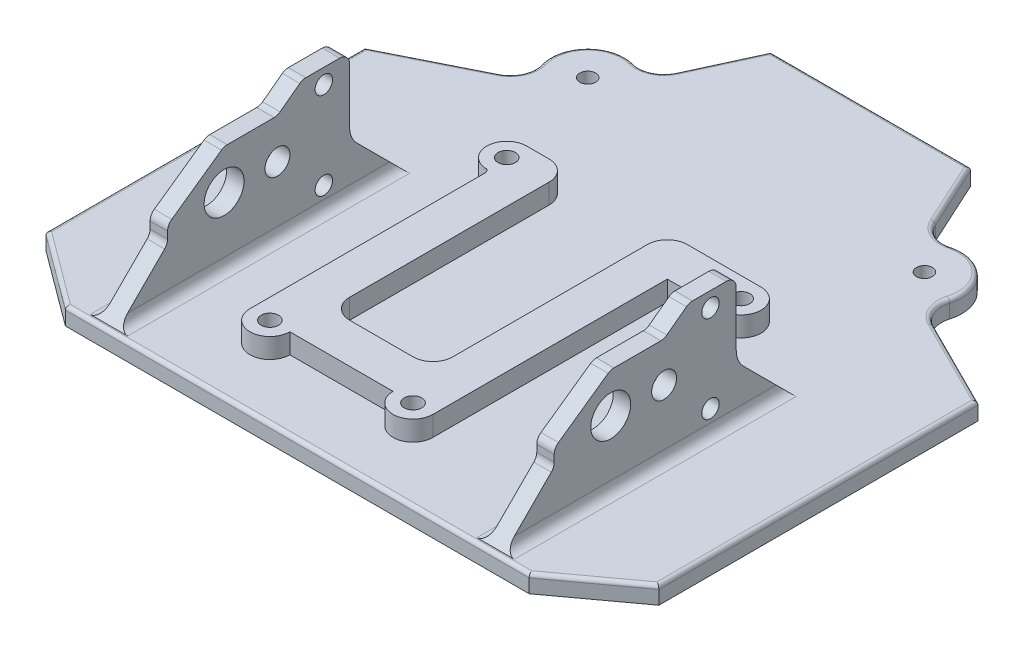
from build123d import *

# Parameters (mm, degrees)
BOSS_EXTRUDE1_DEPTH = 3.5
SKETCH2_W           = 3.5
SKETCH2_H           = 36.5
BOSS_EXTRUDE2_DEPTH = 25
CHAMFER1_SIZE       = 10
FILLET1_R           = 2
SKETCH3_R           = 1.75
CUT_EXTRUDE1_DEPTH  = 108
FILLET2_R           = 2
SKETCH4_R           = 4
SKETCH4_R_2         = 2.5
CUT_EXTRUDE2_DEPTH  = 108
CUT_EXTRUDE3_DEPTH  = 108
FILLET3_R           = 2
FILLET4_R           = 5
SKETCH6_R           = 1.75
BOSS_EXTRUDE3_DEPTH = 4
SKETCH7_R           = 1.75
CUT_EXTRUDE4_DEPTH  = 37
CHAMFER2_SIZE       = 2.5
CHAMFER2_SIZE2      = 2
CUT_EXTRUDE5_DEPTH  = 37
SKETCH9_R           = 1.6
BOSS_EXTRUDE4_DEPTH = 3.5
FILLET5_R           = 5
FILLET6_R           = 0.75


with BuildPart() as part:
    # Sketch1 → Boss-Extrude1 (new body)
    with BuildSketch(Plane(origin=(0, 0, 0), x_dir=(1, 0, 0), z_dir=(0, 1, 0))):
        Polygon((0, 0), (63, 0), (93, 0), (93, 75), (63, 90), (51.5, 115), (31.5, 115), (11.5, 115), (0, 90), (-30, 75), (-30, 0), align=None)
    extrude(amount=BOSS_EXTRUDE1_DEPTH)

    # Sketch2 → Boss-Extrude2 (add)
    with BuildSketch(Plane(origin=(0, 3.5, 0), x_dir=(1, 0, 0), z_dir=(0, 1, 0))):
        with Locations((-7.267018522, 29.254092769)):
            Rectangle(SKETCH2_W, SKETCH2_H)
        with Locations((70.267018522, 29.254092769)):
            Rectangle(SKETCH2_W, SKETCH2_H)
    extrude(amount=BOSS_EXTRUDE2_DEPTH)

    # Chamfer1
    chamfer1_edges = [part.edges().sort_by_distance(p)[0] for p in [
        (-7.267018522, 3.5, -11.004092769),
        (-7.267018522, 3.5, -47.504092769),
        (70.267018522, 3.5, -11.004092769),
        (70.267018522, 3.5, -47.504092769),
    ]]
    chamfer(chamfer1_edges, length=CHAMFER1_SIZE)

    # Fillet1
    fillet1_edges = [part.edges().sort_by_distance(p)[0] for p in [
        (-5.517018522, 3.5, -29.254092769),
        (68.517018522, 3.5, -29.254092769),
    ]]
    fillet(fillet1_edges, radius=FILLET1_R)

    # Sketch3 → Cut-Extrude1 (cut)
    with BuildSketch(Plane(origin=(72.017018522, 0, 0), x_dir=(0, 0, -1), z_dir=(1, 0, 0))):
        with Locations((42.33980963, 25.5)):
            Circle(SKETCH3_R)
        with Locations((42.33980963, 8)):
            Circle(SKETCH3_R)
    extrude(amount=-CUT_EXTRUDE1_DEPTH, mode=Mode.SUBTRACT)

    # Fillet2
    fillet2_edges = [part.edges().sort_by_distance(p)[0] for p in [
        (-9.017018522, 3.5, -29.254092769),
        (72.017018522, 3.5, -29.254092769),
    ]]
    fillet(fillet2_edges, radius=FILLET2_R)

    # Sketch4 → Cut-Extrude2 (cut)
    with BuildSketch(Plane(origin=(72.017018522, 0, 0), x_dir=(0, 0, -1), z_dir=(1, 0, 0))):
        with Locations((22.33980963, 16.75)):
            Circle(SKETCH4_R)
        with Locations((33.03980963, 16.75)):
            Circle(SKETCH4_R_2)
    extrude(amount=-CUT_EXTRUDE2_DEPTH, mode=Mode.SUBTRACT)

    # Sketch5 → Cut-Extrude3 (cut)
    with BuildSketch(Plane(origin=(72.017018522, 0, 0), x_dir=(0, 0, -1), z_dir=(1, 0, 0))):
        Polygon((22.33980963, 24.747503661), (11.004092769, 16.75), (11.004092769, 28.5), (38.0603401, 28.5), (33.03980963, 24.747503661), align=None)
    extrude(amount=-CUT_EXTRUDE3_DEPTH, mode=Mode.SUBTRACT)

    # Fillet3
    fillet3_edges = [part.edges().sort_by_distance(p)[0] for p in [
        (70.267018522, 28.5, -38.0603401),
        (-7.267018522, 24.747503661, -33.03980963),
        (70.267018522, 24.747503661, -33.03980963),
        (-7.267018522, 24.747503661, -22.33980963),
        (70.267018522, 24.747503661, -22.33980963),
        (-7.267018522, 28.5, -38.0603401),
        (-7.267018522, 16.75, -11.004092769),
        (70.267018522, 16.75, -11.004092769),
        (-7.267018522, 28.5, -47.504092769),
        (70.267018522, 28.5, -47.504092769),
        (-7.267018522, 13.5, -11.004092769),
        (70.267018522, 13.5, -11.004092769),
    ]]
    fillet(fillet3_edges, radius=FILLET3_R)

    # Fillet4
    fillet4_edges = [part.edges().sort_by_distance(p)[0] for p in [
        (-7.267018522, 13.5, -47.504092769),
        (70.267018522, 13.5, -47.504092769),
    ]]
    fillet(fillet4_edges, radius=FILLET4_R)

    # Sketch6 → Boss-Extrude3 (add)
    with BuildSketch(Plane(origin=(0, 3.5, 0), x_dir=(1, 0, 0), z_dir=(0, 1, 0))):
        with BuildLine():
            ThreePointArc((8, 14), (12, 10), (16, 14))
            Line((16, 14), (36.7, 14))
            ThreePointArc((36.7, 14), (40.7, 10), (44.7, 14))
            Line((44.7, 14), (44.7, 61))
            Line((44.7, 61), (55.5, 61))
            ThreePointArc((55.5, 61), (59.5, 65), (55.5, 69))
            Line((55.5, 69), (40.7, 69))
            ThreePointArc((40.7, 69), (37.871572875, 67.828427125), (36.7, 65))
            Line((36.7, 65), (36.7, 26))
            ThreePointArc((36.7, 26), (35.528427125, 23.171572875), (32.7, 22))
            Line((32.7, 22), (20, 22))
            ThreePointArc((20, 22), (17.171572875, 23.171572875), (16, 26))
            Line((16, 26), (16, 66))
            ThreePointArc((16, 66), (14.828427125, 68.828427125), (12, 70))
            Line((12, 70), (7.5, 70))
            ThreePointArc((7.5, 70), (3.5, 66), (7.5, 62))
            ThreePointArc((7.5, 62), (7.856858863, 61.606355585), (8, 61.09467718))
            ThreePointArc((8, 61.09467718), (8.000969427, 61.04733859), (8, 61))
            Line((8, 61), (8, 14))
        make_face()
        with Locations((12, 14)):
            Circle(SKETCH6_R, mode=Mode.SUBTRACT)
        with Locations((40.7, 14)):
            Circle(SKETCH6_R, mode=Mode.SUBTRACT)
        with Locations((7.5, 66)):
            Circle(SKETCH6_R, mode=Mode.SUBTRACT)
        with Locations((55.5, 65)):
            Circle(SKETCH6_R, mode=Mode.SUBTRACT)
    extrude(amount=BOSS_EXTRUDE3_DEPTH)

    # Sketch7 → Cut-Extrude4 (cut)
    with BuildSketch(Plane(origin=(0, 7.5, 0), x_dir=(1, 0, 0), z_dir=(0, 1, 0))):
        with Locations((7.5, 66)):
            Circle(SKETCH7_R)
        with Locations((55.5, 65)):
            Circle(SKETCH7_R)
        with Locations((40.7, 14)):
            Circle(SKETCH7_R)
        with Locations((12, 14)):
            Circle(SKETCH7_R)
    extrude(amount=-CUT_EXTRUDE4_DEPTH, mode=Mode.SUBTRACT)

    # Chamfer2
    chamfer2_edges = [part.edges().sort_by_distance(p)[0] for p in [
        (5.75, 0, -66),
        (53.75, 0, -65),
        (38.95, 0, -14),
        (10.25, 0, -14),
    ]]
    chamfer2_side = [part.faces().sort_by_distance(p)[0] for p in [
        (31.50834927, 0, -49.636894868),
    ]]
    chamfer(chamfer2_edges, length=CHAMFER2_SIZE, length2=CHAMFER2_SIZE2, reference=chamfer2_side[0])

    # Sketch8 → Cut-Extrude5 (cut)
    with BuildSketch(Plane(origin=(0, 3.5, 0), x_dir=(1, 0, 0), z_dir=(0, 1, 0))):
        Polygon((-30, 11.112303486), (-15, 0), (-30, 0), align=None)
        Polygon((78, 0), (93, 11.004092769), (93, 0), align=None)
    extrude(amount=-CUT_EXTRUDE5_DEPTH, mode=Mode.SUBTRACT)

    # Sketch9 → Boss-Extrude4 (add)
    with BuildSketch(Plane(origin=(0, 3.5, 0), x_dir=(1, 0, 0), z_dir=(0, 1, 0))):
        with BuildLine():
            Line((-7.230389166, 86.384805417), (0, 90))
            Line((0, 90), (3.257553694, 97.081638464))
            ThreePointArc((3.257553694, 97.081638464), (-7.613842407, 97.250752983), (-7.230389166, 86.384805417))
        make_face()
        with Locations((-2.258509261, 92)):
            Circle(SKETCH9_R, mode=Mode.SUBTRACT)
        with BuildLine():
            Line((59.742446306, 97.081638464), (63, 90))
            Line((63, 90), (70.230389166, 86.384805417))
            ThreePointArc((70.230389166, 86.384805417), (70.613842407, 97.250752983), (59.742446306, 97.081638464))
        make_face()
        with Locations((65.258509261, 92)):
            Circle(SKETCH9_R, mode=Mode.SUBTRACT)
    extrude(amount=-BOSS_EXTRUDE4_DEPTH)

    # Fillet5
    fillet5_edges = [part.edges().sort_by_distance(p)[0] for p in [
        (3.257553694, 1.75, -97.081638464),
        (-7.230389166, 1.75, -86.384805417),
        (70.230389166, 1.75, -86.384805417),
        (59.742446306, 1.75, -97.081638464),
    ]]
    fillet(fillet5_edges, radius=FILLET5_R)

    # Fillet6
    fillet6_edges = [part.edges().sort_by_distance(p)[0] for p in [
        (84.006223284, 3.5, -79.496888358),
        (31.5, 3.5, -115),
        (8.506790147, 3.5, -108.493022059),
        (-30, 3.5, -43.056151743),
        (31.5, 3.5, 0),
        (-22.5, 3.5, -5.556151743),
        (93, 3.5, -43.002046385),
        (85.5, 3.5, -5.502046385),
        (70.628471691, 3.5, -97.235790627),
        (54.493209853, 3.5, -108.493022059),
        (-7.628471691, 3.5, -97.235790627),
        (-21.006223284, 3.5, -79.496888358),
        (59.902970742, 3.5, -99.550028659),
        (72.663421616, 3.5, -86.47169031),
        (3.097029258, 3.5, -99.550028659),
        (-9.663421616, 3.5, -86.47169031),
    ]]
    fillet(fillet6_edges, radius=FILLET6_R)


solid = part.part
